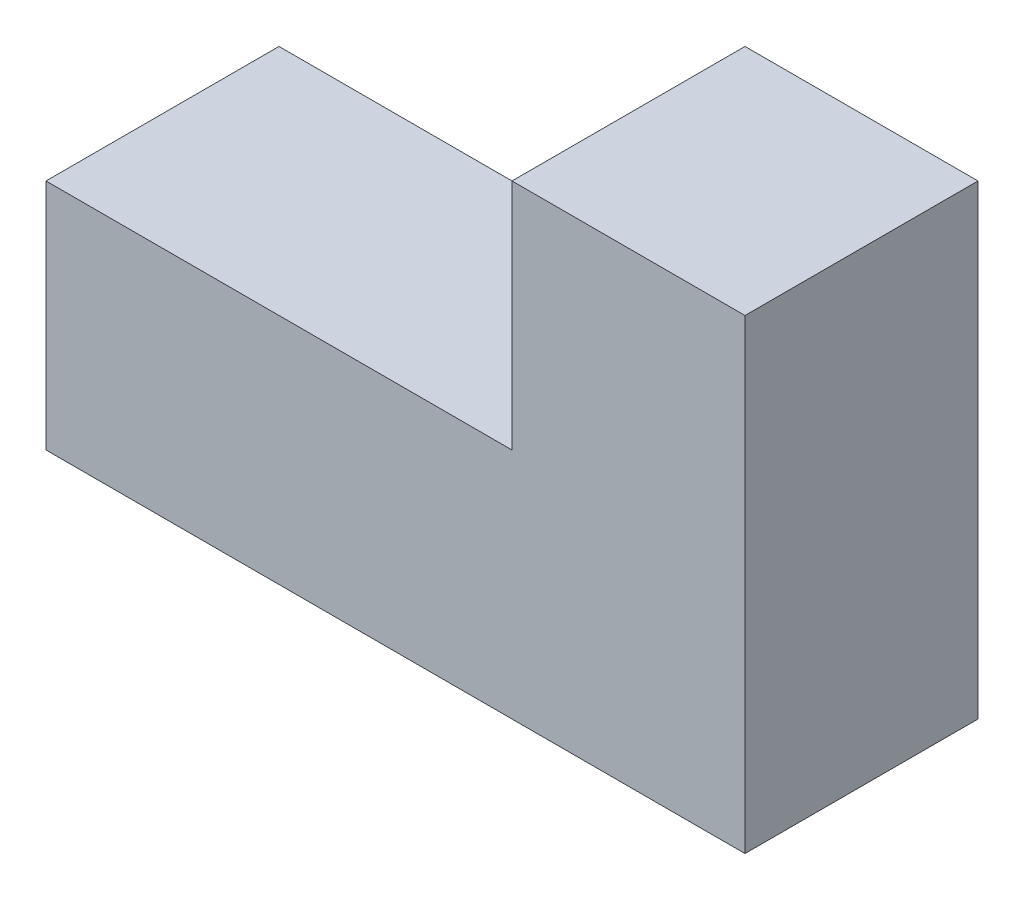
from build123d import *

# Parameters (mm, degrees)
BOSS_EXTRU_1_DEPTH = 30


with BuildPart() as part:
    # Esquisse2 → Boss.-Extru.1 (new body)
    with BuildSketch(Plane.XY):
        Polygon((0, 0), (90, 0), (90, 60), (60, 60), (60, 30), (0, 30), align=None)
    extrude(amount=BOSS_EXTRU_1_DEPTH)


solid = part.part
